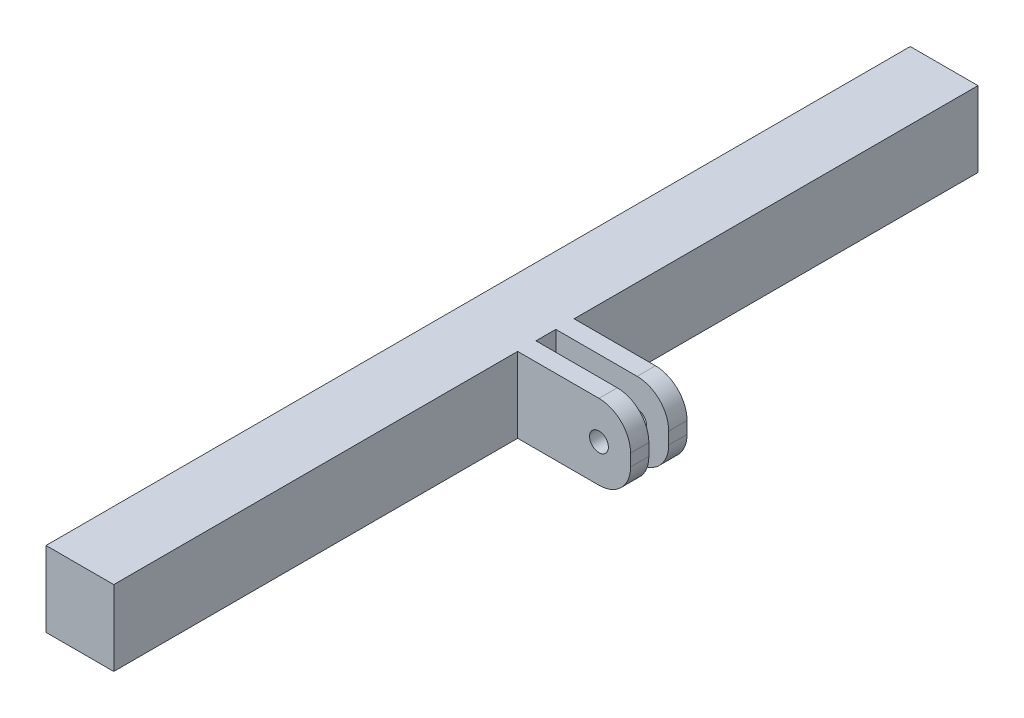
from build123d import *

# Parameters (mm, degrees)
SKETCH1_W                = 11.43
SKETCH1_H                = 12.7
BOSS_EXTRUDE1_DEPTH      = 72.898
BOSS_EXTRUDE1_DEPTH_BACK = 72.898
SKETCH2_R                = 1.5875
BOSS_EXTRUDE2_DEPTH      = 4.7625
BOSS_EXTRUDE2_DEPTH_BACK = 4.7625
CUT_EXTRUDE1_DEPTH       = 1.6764
CUT_EXTRUDE1_DEPTH_BACK  = 1.6764


with BuildPart() as part:
    # Sketch1 → Boss-Extrude1 (new body, two sides)
    with BuildSketch(Plane.XY) as boss_extrude1_sk:
        with Locations((5.715, -6.35)):
            Rectangle(SKETCH1_W, SKETCH1_H)
    extrude(amount=BOSS_EXTRUDE1_DEPTH)
    extrude(boss_extrude1_sk.sketch, amount=-BOSS_EXTRUDE1_DEPTH_BACK)

    # Sketch2 → Boss-Extrude2 (add, two sides)
    with BuildSketch(Plane.XY) as boss_extrude2_sk:
        with BuildLine():
            Line((11.43, 0), (25.146, 0))
            ThreePointArc((25.146, 0), (28.917707571, -1.562292429), (30.48, -5.334))
            Line((30.48, -5.334), (30.48, -7.366))
            ThreePointArc((30.48, -7.366), (28.917707571, -11.137707571), (25.146, -12.7))
            Line((25.146, -12.7), (11.43, -12.7))
            Line((11.43, -12.7), (11.43, 0))
        make_face()
        with Locations((25.146, -6.35)):
            Circle(SKETCH2_R, mode=Mode.SUBTRACT)
    extrude(amount=BOSS_EXTRUDE2_DEPTH)
    extrude(boss_extrude2_sk.sketch, amount=-BOSS_EXTRUDE2_DEPTH_BACK)

    # Sketch3 → Cut-Extrude1 (cut, two sides)
    with BuildSketch(Plane.XY) as cut_extrude1_sk:
        with BuildLine():
            Line((11.43, 0), (11.43, -12.7))
            Line((11.43, -12.7), (25.146, -12.7))
            ThreePointArc((25.146, -12.7), (28.917707571, -11.137707571), (30.48, -7.366))
            Line((30.48, -7.366), (30.48, -5.334))
            ThreePointArc((30.48, -5.334), (28.917707571, -1.562292429), (25.146, 0))
            Line((25.146, 0), (11.43, 0))
        make_face()
    extrude(amount=CUT_EXTRUDE1_DEPTH, mode=Mode.SUBTRACT)
    extrude(cut_extrude1_sk.sketch, amount=-CUT_EXTRUDE1_DEPTH_BACK, mode=Mode.SUBTRACT)


solid = part.part
